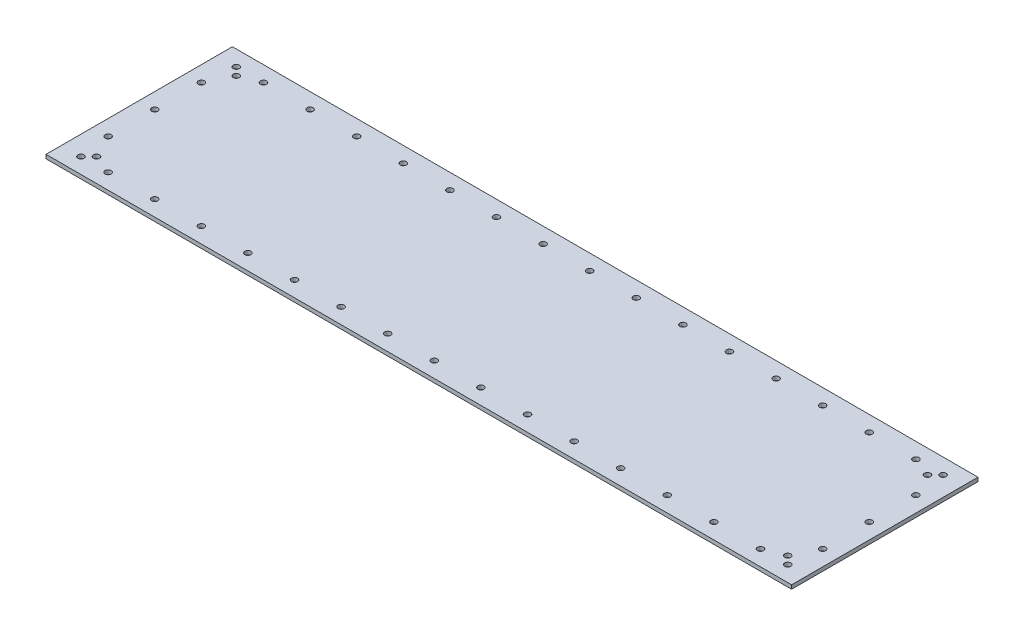
from build123d import *

# Parameters (mm, degrees)
SKETCH1_W           = 609.6
SKETCH1_H           = 152.4
BOSS_EXTRUDE1_DEPTH = 3.175
SKETCH2_R           = 2.5
CUT_EXTRUDE1_DEPTH  = 3.175


with BuildPart() as part:
    # Sketch1 → Boss-Extrude1 (new body)
    with BuildSketch(Plane(origin=(0, 0, 0), x_dir=(1, 0, 0), z_dir=(0, 1, 0))):
        Rectangle(SKETCH1_W, SKETCH1_H)
    extrude(amount=BOSS_EXTRUDE1_DEPTH)

    # Sketch2 → Cut-Extrude1 (cut)
    with BuildSketch(Plane(origin=(0, 3.175, 0), x_dir=(1, 0, 0), z_dir=(0, 1, 0))):
        with Locations((-288.925, 63.5)):
            Circle(SKETCH2_R)
        with Locations((-282.575, 57.15)):
            Circle(SKETCH2_R)
        with Locations((282.575, 57.15)):
            Circle(SKETCH2_R)
        with Locations((288.925, 63.5)):
            Circle(SKETCH2_R)
        with Locations((-266.7, 63.5)):
            Circle(SKETCH2_R)
        with Locations((-228.6, 63.5)):
            Circle(SKETCH2_R)
        with Locations((-190.5, 63.5)):
            Circle(SKETCH2_R)
        with Locations((-152.4, 63.5)):
            Circle(SKETCH2_R)
        with Locations((-114.3, 63.5)):
            Circle(SKETCH2_R)
        with Locations((-76.2, 63.5)):
            Circle(SKETCH2_R)
        with Locations((-38.1, 63.5)):
            Circle(SKETCH2_R)
        with Locations((0, 63.5)):
            Circle(SKETCH2_R)
        with Locations((38.1, 63.5)):
            Circle(SKETCH2_R)
        with Locations((76.2, 63.5)):
            Circle(SKETCH2_R)
        with Locations((114.3, 63.5)):
            Circle(SKETCH2_R)
        with Locations((-292.1, 38.1)):
            Circle(SKETCH2_R)
        with Locations((-292.1, 0)):
            Circle(SKETCH2_R)
        with Locations((-292.1, -38.1)):
            Circle(SKETCH2_R)
        with Locations((292.1, -38.1)):
            Circle(SKETCH2_R)
        with Locations((292.1, 0)):
            Circle(SKETCH2_R)
        with Locations((292.1, 38.1)):
            Circle(SKETCH2_R)
        with Locations((152.4, 63.5)):
            Circle(SKETCH2_R)
        with Locations((190.5, 63.5)):
            Circle(SKETCH2_R)
        with Locations((228.6, 63.5)):
            Circle(SKETCH2_R)
        with Locations((266.7, 63.5)):
            Circle(SKETCH2_R)
        with Locations((266.7, -63.5)):
            Circle(SKETCH2_R)
        with Locations((228.6, -63.5)):
            Circle(SKETCH2_R)
        with Locations((190.5, -63.5)):
            Circle(SKETCH2_R)
        with Locations((152.4, -63.5)):
            Circle(SKETCH2_R)
        with Locations((114.3, -63.5)):
            Circle(SKETCH2_R)
        with Locations((76.2, -63.5)):
            Circle(SKETCH2_R)
        with Locations((38.1, -63.5)):
            Circle(SKETCH2_R)
        with Locations((0, -63.5)):
            Circle(SKETCH2_R)
        with Locations((-38.1, -63.5)):
            Circle(SKETCH2_R)
        with Locations((-76.2, -63.5)):
            Circle(SKETCH2_R)
        with Locations((-114.3, -63.5)):
            Circle(SKETCH2_R)
        with Locations((-152.4, -63.5)):
            Circle(SKETCH2_R)
        with Locations((-190.5, -63.5)):
            Circle(SKETCH2_R)
        with Locations((-228.6, -63.5)):
            Circle(SKETCH2_R)
        with Locations((-266.7, -63.5)):
            Circle(SKETCH2_R)
        with Locations((288.925, -63.5)):
            Circle(SKETCH2_R)
        with Locations((282.575, -57.15)):
            Circle(SKETCH2_R)
        with Locations((-282.575, -57.15)):
            Circle(SKETCH2_R)
        with Locations((-288.925, -63.5)):
            Circle(SKETCH2_R)
    extrude(amount=-CUT_EXTRUDE1_DEPTH, mode=Mode.SUBTRACT)


solid = part.part
